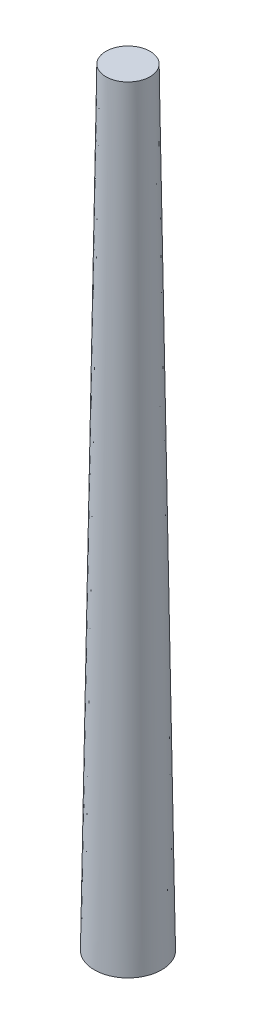
from build123d import *


with BuildPart() as part:
    # Sketch1 → Revolve1 (revolve)
    with BuildSketch(Plane.XY):
        Polygon((0, 0), (6.5405, 0), (4.28625, 149.225), (0, 149.225), align=None)
    revolve(axis=Axis((0, 149.225, 0), (0, -1, 0)))


solid = part.part
